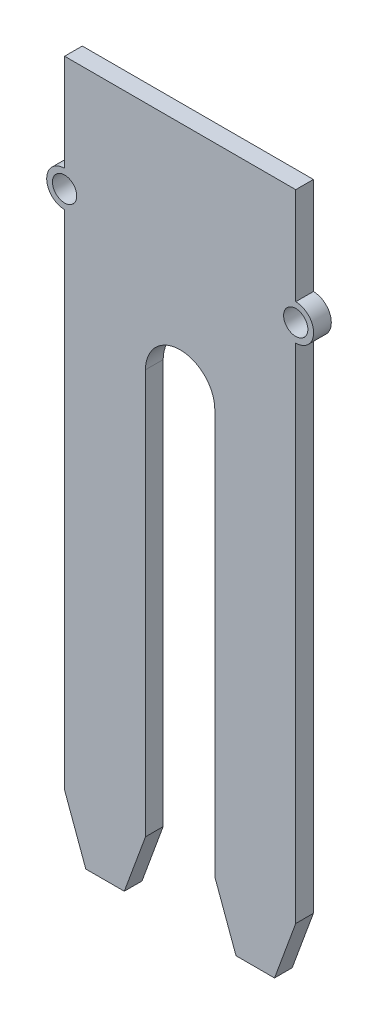
from build123d import *

# Parameters (mm, degrees)
ESQUISSE1_R        = 1.05
BOSS_EXTRU_1_DEPTH = 1.53


with BuildPart() as part:
    # Esquisse1 → Boss.-Extru.1 (new body)
    with BuildSketch(Plane.XY):
        with BuildLine():
            Line((10.206015929, 5), (10.206015929, 40))
            ThreePointArc((10.206015929, 40), (7.206015929, 43), (4.206015929, 40))
            Line((4.206015929, 40), (4.206015929, 5))
            Line((4.206015929, 5), (2.371015929, 0))
            Line((2.371015929, 0), (0.706015929, 0))
            Line((0.706015929, 0), (-0.958984071, 0))
            Line((-0.958984071, 0), (-2.793984071, 5))
            Line((-2.793984071, 5), (-2.793984071, 48.5))
            ThreePointArc((-2.793984071, 48.5), (-4.343984071, 50.05), (-2.793984071, 51.6))
            Line((-2.793984071, 51.6), (-2.793984071, 60))
            Line((-2.793984071, 60), (17.206015929, 60))
            Line((17.206015929, 60), (17.206015929, 51.6))
            ThreePointArc((17.206015929, 51.6), (18.756015929, 50.05), (17.206015929, 48.5))
            Line((17.206015929, 48.5), (17.206015929, 5))
            Line((17.206015929, 5), (15.371015929, 0))
            Line((15.371015929, 0), (13.706015929, 0))
            Line((13.706015929, 0), (12.041015929, 0))
            Line((12.041015929, 0), (10.206015929, 5))
        make_face()
        with Locations((17.206015929, 50.05)):
            Circle(ESQUISSE1_R, mode=Mode.SUBTRACT)
        with Locations((-2.793984071, 50.05)):
            Circle(ESQUISSE1_R, mode=Mode.SUBTRACT)
    extrude(amount=BOSS_EXTRU_1_DEPTH)


solid = part.part
